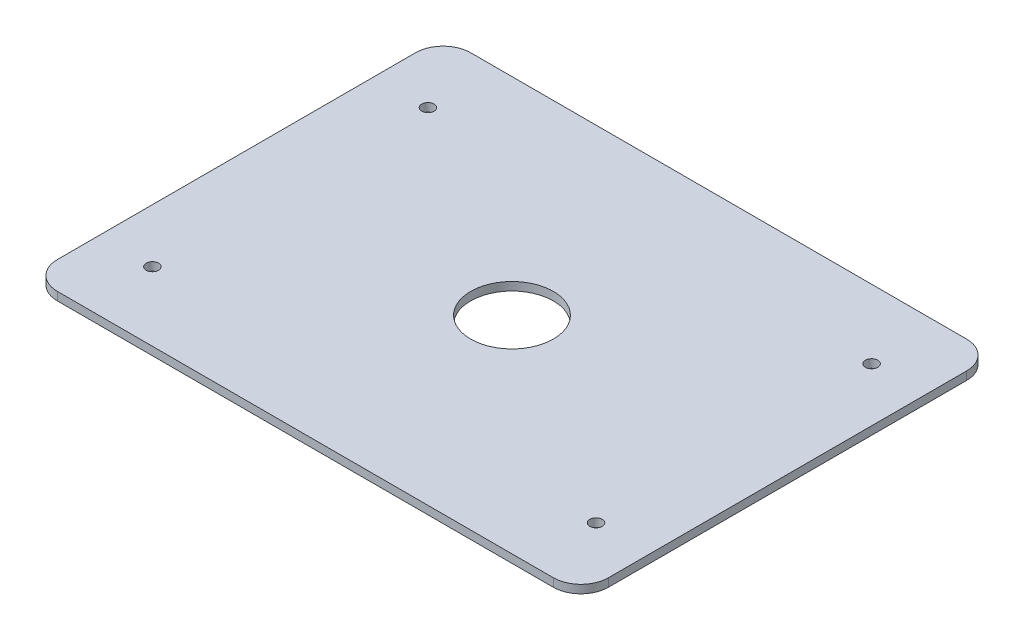
from build123d import *

# Parameters (mm, degrees)
SKETCH1_W           = 200
SKETCH1_H           = 150
SKETCH1_R           = 2.25
SKETCH1_R_2         = 15
BOSS_EXTRUDE1_DEPTH = 3
FILLET1_R           = 10


with BuildPart() as part:
    # Sketch1 → Boss-Extrude1 (new body)
    with BuildSketch(Plane(origin=(0, 0, 0), x_dir=(1, 0, 0), z_dir=(0, 1, 0))):
        with Locations((45.2, -135.43)):
            Rectangle(SKETCH1_W, SKETCH1_H)
        with Locations((-35.3, -85.43)):
            Circle(SKETCH1_R, mode=Mode.SUBTRACT)
        with Locations((125.7, -85.43)):
            Circle(SKETCH1_R, mode=Mode.SUBTRACT)
        with Locations((125.7, -185.43)):
            Circle(SKETCH1_R, mode=Mode.SUBTRACT)
        with Locations((-35.3, -185.43)):
            Circle(SKETCH1_R, mode=Mode.SUBTRACT)
        with Locations((45.2, -135.43)):
            Circle(SKETCH1_R_2, mode=Mode.SUBTRACT)
    extrude(amount=BOSS_EXTRUDE1_DEPTH)

    # Fillet1
    fillet1_edges = [part.edges().sort_by_distance(p)[0] for p in [
        (145.2, 1.5, 210.43),
        (-54.8, 1.5, 210.43),
        (-54.8, 1.5, 60.43),
        (145.2, 1.5, 60.43),
    ]]
    fillet(fillet1_edges, radius=FILLET1_R)


solid = part.part
